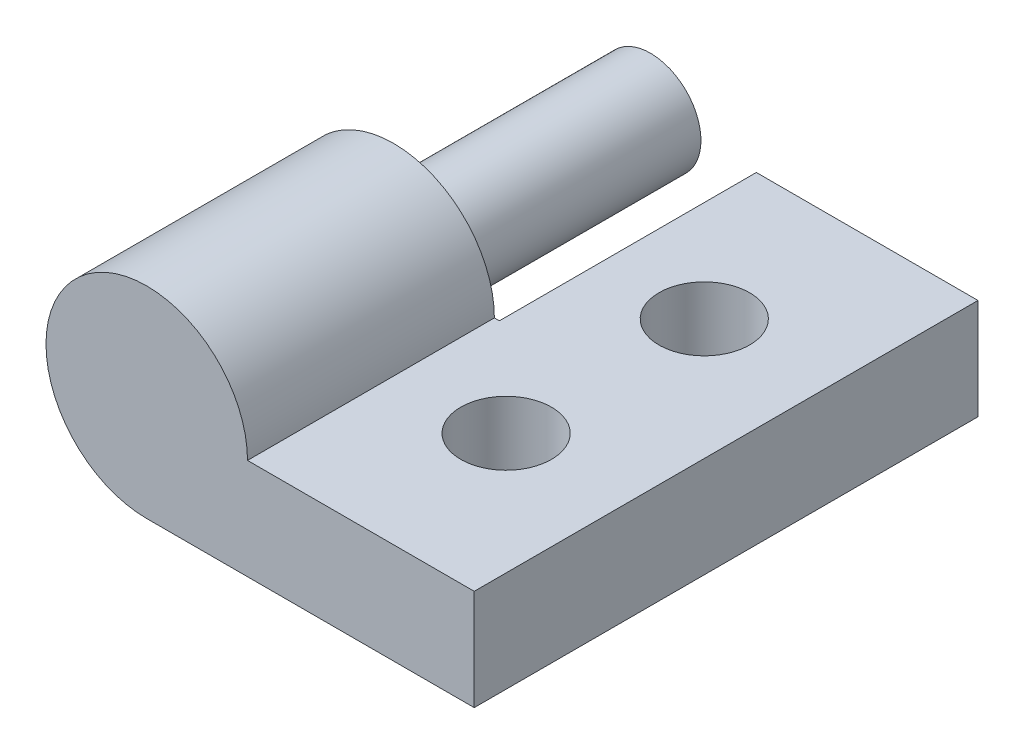
from build123d import *

# Parameters (mm, degrees)
BOSS_EXTRUDE1_DEPTH = 25.4
SKETCH5_R           = 2.286
CUT_EXTRUDE3_DEPTH  = 12.954
SKETCH8_R           = 5.334
CUT_EXTRUDE5_DEPTH  = 12.954
SKETCH9_R           = 2.54
BOSS_EXTRUDE2_DEPTH = 12.954
CUT_EXTRUDE7_DEPTH  = 12.954


with BuildPart() as part:
    # Sketch2 → Boss-Extrude1 (new body)
    with BuildSketch(Plane.XY):
        with BuildLine():
            Line((0, 0), (-16.51, 0))
            ThreePointArc((-16.51, 0), (-20.102102448, 8.672102448), (-11.43, 5.08))
            Line((-11.43, 5.08), (0, 5.08))
            Line((0, 5.08), (0, 0))
        make_face()
    extrude(amount=BOSS_EXTRUDE1_DEPTH)

    # Sketch5 → Cut-Extrude3 (cut)
    with BuildSketch(Plane(origin=(0, 5.08, 0), x_dir=(1, 0, 0), z_dir=(0, 1, 0))):
        with Locations((-6.096, -17.695333333)):
            Circle(SKETCH5_R)
        with Locations((-6.096, -7.704666667)):
            Circle(SKETCH5_R)
    extrude(amount=-CUT_EXTRUDE3_DEPTH, mode=Mode.SUBTRACT)

    # Sketch8 → Cut-Extrude5 (cut)
    with BuildSketch(Plane(origin=(0, 0, 0), x_dir=(-1, 0, 0), z_dir=(0, 0, -1))):
        with Locations((16.51, 5.08)):
            Circle(SKETCH8_R)
    extrude(amount=-CUT_EXTRUDE5_DEPTH, mode=Mode.SUBTRACT)

    # Sketch9 → Boss-Extrude2 (add)
    with BuildSketch(Plane(origin=(0, 0, 12.954), x_dir=(-1, 0, 0), z_dir=(0, 0, -1))):
        with Locations((16.51, 5.08)):
            Circle(SKETCH9_R)
    extrude(amount=BOSS_EXTRUDE2_DEPTH)

    # Sketch10 → Cut-Extrude7 (cut)
    with BuildSketch(Plane(origin=(0, 0, 0), x_dir=(-1, 0, 0), z_dir=(0, 0, -1))):
        with BuildLine():
            Line((11.176, 5.08), (11.176, 0))
            Line((11.176, 0), (14.883606444, 0))
            ThreePointArc((14.883606444, 0), (12.201477096, 1.935451322), (11.176, 5.08))
        make_face()
    extrude(amount=-CUT_EXTRUDE7_DEPTH, mode=Mode.SUBTRACT)


solid = part.part
